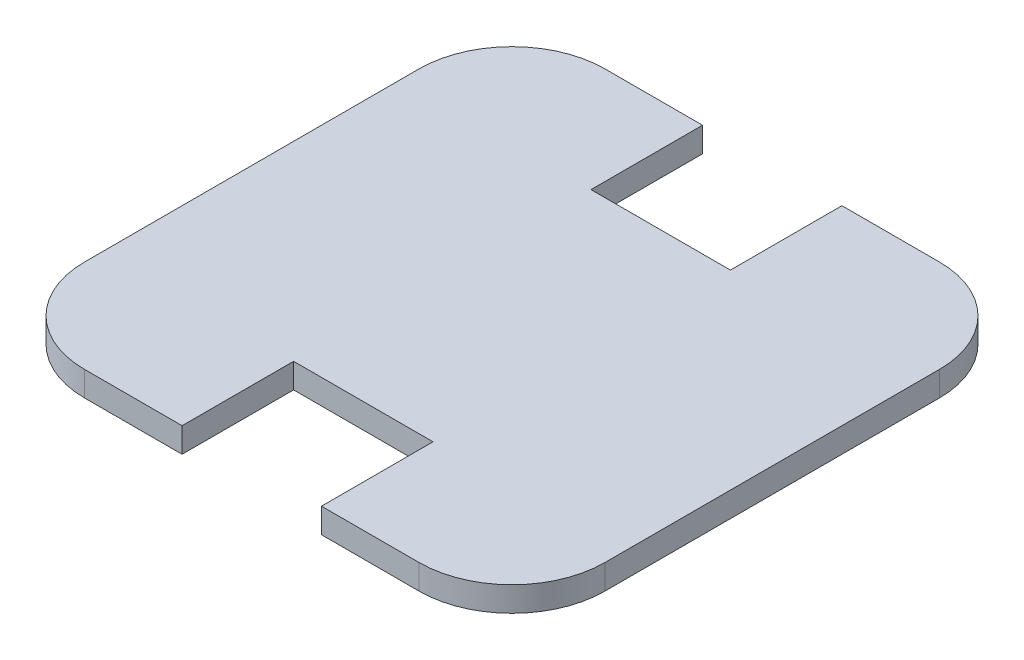
from build123d import *

# Parameters (mm, degrees)
BOSS_EXTRUDE1_DEPTH = 4


with BuildPart() as part:
    # Layer1 → Boss-Extrude1 (new body)
    with BuildSketch(Plane(origin=(0, 0, 0), x_dir=(1, 0, 0), z_dir=(0, 1, 0))):
        with BuildLine():
            Line((27, 42), (11.25, 42))
            Line((11.25, 42), (11.25, 24))
            Line((11.25, 24), (-11.25, 24))
            Line((-11.25, 24), (-11.25, 42))
            Line((-11.25, 42), (-27, 42))
            ThreePointArc((-27, 42), (-37.606601718, 37.606601718), (-42, 27))
            Line((-42, 27), (-42, 21.5))
            Line((-42, 21.5), (-42, -21.5))
            Line((-42, -21.5), (-42, -27))
            ThreePointArc((-42, -27), (-37.606601718, -37.606601718), (-27, -42))
            Line((-27, -42), (-11.25, -42))
            Line((-11.25, -42), (-11.25, -24))
            Line((-11.25, -24), (11.25, -24))
            Line((11.25, -24), (11.25, -42))
            Line((11.25, -42), (27, -42))
            ThreePointArc((27, -42), (37.606601718, -37.606601718), (42, -27))
            Line((42, -27), (42, 27))
            ThreePointArc((42, 27), (37.606601718, 37.606601718), (27, 42))
        make_face()
    extrude(amount=BOSS_EXTRUDE1_DEPTH)


solid = part.part
